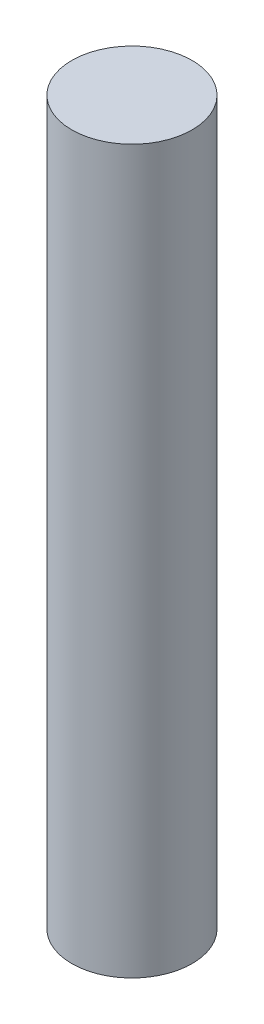
from build123d import *

# Parameters (mm, degrees)
SKETCH1_R           = 2
BOSS_EXTRUDE1_DEPTH = 24


with BuildPart() as part:
    # Sketch1 → Boss-Extrude1 (new body)
    with BuildSketch(Plane(origin=(0, 0, 0), x_dir=(1, 0, 0), z_dir=(0, 1, 0))):
        Circle(SKETCH1_R)
    extrude(amount=BOSS_EXTRUDE1_DEPTH)


solid = part.part
